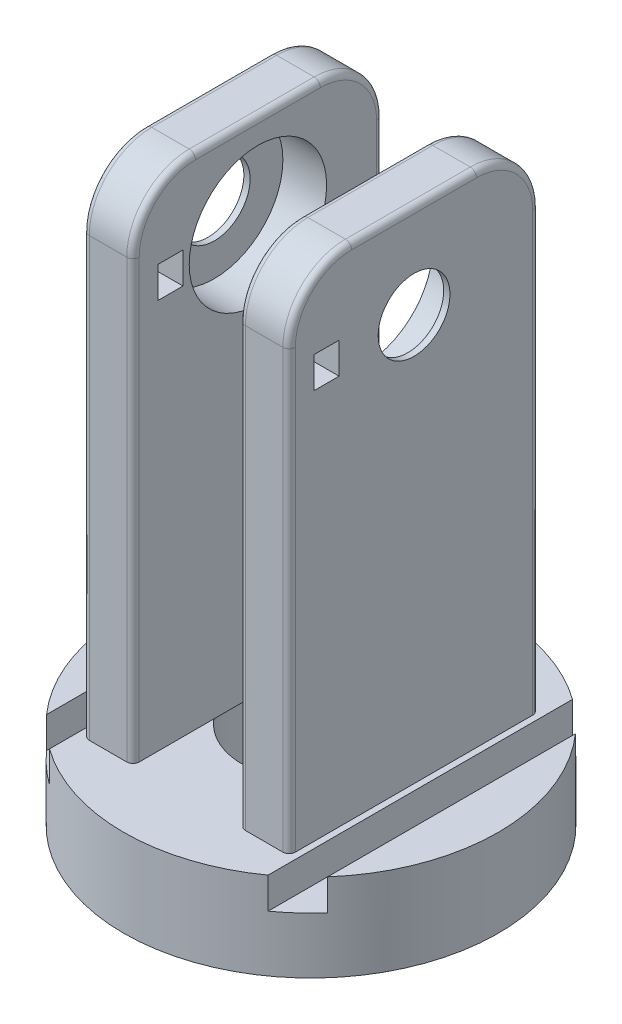
from build123d import *

# Parameters (mm, degrees)
SKETCH1_R               = 30
BOSS_EXTRUDE1_DEPTH     = 14
SKETCH2_R               = 11.05
CUT_EXTRUDE1_DEPTH      = 15
SKETCH5_W               = 8
SKETCH5_H               = 40
BOSS_EXTRUDE2_DEPTH     = 80
FILLET1_R               = 10
SKETCH12_R              = 11
CUT_EXTRUDE5_DEPTH      = 15.5
CUT_EXTRUDE5_DEPTH_BACK = 15.5
SKETCH13_R              = 5.75
CUT_EXTRUDE6_DEPTH      = 33
SKETCH14_W              = 5
SKETCH14_H              = 60.1
CUT_EXTRUDE7_DEPTH      = 5
FILLET2_R               = 1
FILLET3_R               = 1
SKETCH15_W              = 4
SKETCH15_H              = 5
CUT_EXTRUDE14_DEPTH     = 33


with BuildPart() as part:
    # Sketch1 → Boss-Extrude1 (new body)
    with BuildSketch(Plane(origin=(0, 0, 0), x_dir=(1, 0, 0), z_dir=(0, 1, 0))):
        Circle(SKETCH1_R)
    extrude(amount=BOSS_EXTRUDE1_DEPTH)

    # Sketch2 → Cut-Extrude1 (cut, through all)
    with BuildSketch(Plane.XZ):
        Circle(SKETCH2_R)
    extrude(amount=-CUT_EXTRUDE1_DEPTH, mode=Mode.SUBTRACT)

    # Sketch5 → Boss-Extrude2 (add)
    with BuildSketch(Plane(origin=(0, 14, 0), x_dir=(1, 0, 0), z_dir=(0, 1, 0))):
        with Locations((-12.5, 0)):
            Rectangle(SKETCH5_W, SKETCH5_H)
        with Locations((12.5, 0)):
            Rectangle(SKETCH5_W, SKETCH5_H)
    extrude(amount=BOSS_EXTRUDE2_DEPTH)

    # Fillet1
    fillet1_edges = [part.edges().sort_by_distance(p)[0] for p in [
        (-12.5, 94, 20),
        (-12.5, 94, -20),
        (12.5, 94, 20),
        (12.5, 94, -20),
    ]]
    fillet(fillet1_edges, radius=FILLET1_R)

    # Sketch12 → Cut-Extrude5 (cut, two sides)
    with BuildSketch(Plane(origin=(0, 0, 0), x_dir=(0, 0, -1), z_dir=(1, 0, 0))) as cut_extrude5_sk:
        with Locations((0, 79)):
            Circle(SKETCH12_R)
    extrude(amount=CUT_EXTRUDE5_DEPTH, mode=Mode.SUBTRACT)
    extrude(cut_extrude5_sk.sketch, amount=-CUT_EXTRUDE5_DEPTH_BACK, mode=Mode.SUBTRACT)

    # Sketch13 → Cut-Extrude6 (cut)
    with BuildSketch(Plane.ZY.offset(16.5)):
        with Locations((0, 79)):
            Circle(SKETCH13_R)
    extrude(amount=-CUT_EXTRUDE6_DEPTH, mode=Mode.SUBTRACT)

    # Sketch14 → Cut-Extrude7 (cut)
    with BuildSketch(Plane(origin=(0, 14, 0), x_dir=(1, 0, 0), z_dir=(0, 1, 0))):
        with Locations((-20, 0)):
            Rectangle(SKETCH14_W, SKETCH14_H)
        with Locations((20, 0)):
            Rectangle(SKETCH14_W, SKETCH14_H)
    extrude(amount=-CUT_EXTRUDE7_DEPTH, mode=Mode.SUBTRACT)

    # Fillet2
    fillet2_edges = [part.edges().sort_by_distance(p)[0] for p in [
        (-16.5, 94, 0),
        (-16.5, 49, 20),
        (-16.5, 49, -20),
        (-16.5, 91.071067812, 17.071067812),
        (-16.5, 91.071067812, -17.071067812),
        (16.5, 94, 0),
        (16.5, 49, -20),
        (16.5, 49, 20),
        (16.5, 91.071067812, 17.071067812),
        (16.5, 91.071067812, -17.071067812),
    ]]
    fillet(fillet2_edges, radius=FILLET2_R)

    # Fillet3
    fillet3_edges = [part.edges().sort_by_distance(p)[0] for p in [
        (-8.5, 94, 0),
        (-8.5, 49, -20),
        (-8.5, 49, 20),
        (-8.5, 91.071067812, 17.071067812),
        (-8.5, 91.071067812, -17.071067812),
        (8.5, 94, 0),
        (8.5, 49, 20),
        (8.5, 49, -20),
        (8.5, 91.071067812, 17.071067812),
        (8.5, 91.071067812, -17.071067812),
    ]]
    fillet(fillet3_edges, radius=FILLET3_R)

    # Sketch15 → Cut-Extrude14 (cut)
    with BuildSketch(Plane(origin=(16.5, 0, 0), x_dir=(0, 0, -1), z_dir=(1, 0, 0))):
        with Locations((-14, 79)):
            Rectangle(SKETCH15_W, SKETCH15_H)
    extrude(amount=-CUT_EXTRUDE14_DEPTH, mode=Mode.SUBTRACT)


solid = part.part
